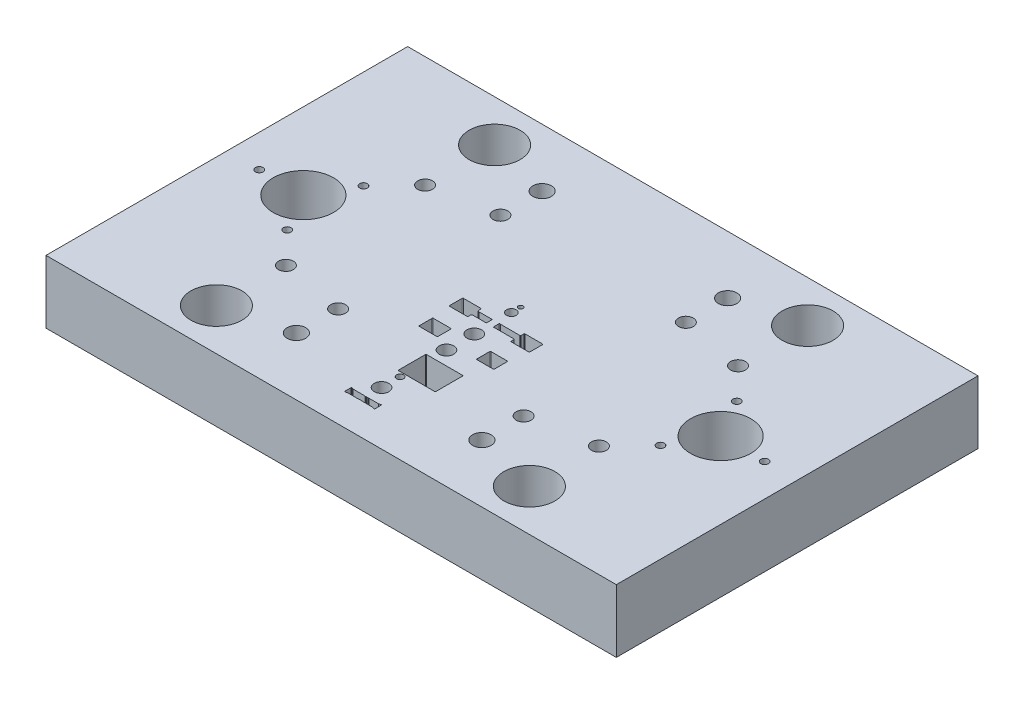
from build123d import *

# Parameters (mm, degrees)
SKETCH1_W                                           = 246
SKETCH1_H                                           = 27.2
EXTRUDE1_DEPTH                                      = 78
HOLE4_D                                             = 26
HOLE4_DEPTH                                         = 30
LPATTERN4_COUNT                                     = 2
LPATTERN4_PITCH                                     = 180
HOLE5_D                                             = 6.4
HOLE5_DEPTH                                         = 100
HOLE5_CBORE_D                                       = 25
HOLE5_CBORE_DEPTH                                   = 12
CUT_EXTRUDE4_DEPTH                                  = 1
LPATTERN5_COUNT                                     = 2
LPATTERN5_PITCH                                     = 60
LPATTERN5_COUNT_DIR2                                = 2
LPATTERN5_PITCH_DIR2                                = 135
CBORE_FOR_M6_HEX_SOCKET_HEAD_CAP_SCREW1_D           = 6.4
CBORE_FOR_M6_HEX_SOCKET_HEAD_CAP_SCREW1_CBORE_D     = 11
CBORE_FOR_M6_HEX_SOCKET_HEAD_CAP_SCREW1_CBORE_DEPTH = 8
HOLE6_D                                             = 8
M4_TAPPED_HOLE1_D                                   = 3.3
HOLE7_D                                             = 22
CUT_EXTRUDE5_DEPTH                                  = 28.2
HOLE8_D                                             = 4.2
HOLE8_DEPTH                                         = 20
HOLE9_D                                             = 6.3
HOLE9_DEPTH                                         = 20
HOLE10_D                                            = 2.06
HOLE11_D                                            = 1.5
HOLE11_CBORE_D                                      = 3
HOLE11_CBORE_DEPTH                                  = 18
SKETCH38_W                                          = 21
SKETCH38_H                                          = 23
CUT_EXTRUDE6_DEPTH                                  = 6
CUT_EXTRUDE7_DEPTH                                  = 6
SKETCH40_R                                          = 2
CUT_EXTRUDE8_DEPTH                                  = 6
M3_TAPPED_HOLE1_D                                   = 2.5
M3_TAPPED_HOLE1_DEPTH                               = 7.5
M3_TAPPED_HOLE1_TIP                                 = 0.751075774


with BuildPart() as part:
    # Sketch1 → Extrude1 (new body, symmetric)
    with BuildSketch(Plane.XY):
        with Locations((0, 13.6)):
            Rectangle(SKETCH1_W, SKETCH1_H)
    extrude(amount=EXTRUDE1_DEPTH, both=True)

    # Hole4
    with Locations(Plane.XZ):
        with Locations((90, 0)):
            hole4 = Hole(HOLE4_D / 2, depth=HOLE4_DEPTH)

    # LPattern4: Hole4 ×2
    with Locations(*[(-i * LPATTERN4_PITCH, 0, 0) for i in range(1, LPATTERN4_COUNT)]):
        add(hole4, mode=Mode.SUBTRACT)

    # Hole5
    with Locations(Plane.XZ):
        with Locations((-67.5, -30)):
            hole5 = CounterBoreHole(HOLE5_D / 2, HOLE5_CBORE_D / 2, HOLE5_CBORE_DEPTH, depth=HOLE5_DEPTH)

    # Sketch17 → Cut-Extrude4 (cut)
    with BuildSketch(Plane.XZ):
        with BuildLine():
            Line((-20, 70), (-20, -70))
            ThreePointArc((-20, -70), (-18.535533906, -73.535533906), (-15, -75))
            Line((-15, -75), (15, -75))
            ThreePointArc((15, -75), (18.535533906, -73.535533906), (20, -70))
            Line((20, -70), (20, 70))
            ThreePointArc((20, 70), (18.535533906, 73.535533906), (15, 75))
            Line((15, 75), (-15, 75))
            ThreePointArc((-15, 75), (-18.535533906, 73.535533906), (-20, 70))
        make_face()
    extrude(amount=-CUT_EXTRUDE4_DEPTH, mode=Mode.SUBTRACT)

    # LPattern5: Hole5 2 × 2
    with Locations(*[(j * LPATTERN5_PITCH_DIR2, 0, i * LPATTERN5_PITCH) for i in range(LPATTERN5_COUNT) for j in range(LPATTERN5_COUNT_DIR2) if (i, j) != (0, 0)]):
        add(hole5, mode=Mode.SUBTRACT)

    # CBORE for M6 Hex Socket Head Cap Screw1 (through all)
    with Locations(Plane.XZ):
        with Locations((40, 35), (40, -35), (-40, -35), (-40, 35)):
            CounterBoreHole(CBORE_FOR_M6_HEX_SOCKET_HEAD_CAP_SCREW1_D / 2, CBORE_FOR_M6_HEX_SOCKET_HEAD_CAP_SCREW1_CBORE_D / 2, CBORE_FOR_M6_HEX_SOCKET_HEAD_CAP_SCREW1_CBORE_DEPTH)

    # Hole6 (through all)
    with Locations(Plane.XZ):
        with Locations((40, 53), (-40, 53), (-40, -53), (40, -53)):
            Hole(HOLE6_D / 2)

    # M4 Tapped Hole1 (through all)
    with Locations(Plane.XZ):
        with Locations((-80.5, 16.454482672), (-80.5, -16.454482672), (-109, 0), (109, 0), (80.5, 16.454482672), (80.5, -16.454482672)):
            Hole(M4_TAPPED_HOLE1_D / 2)

    # Hole7 (through all)
    with Locations(Plane.XZ):
        with Locations((-67.5, 60), (67.5, 60), (67.5, -60), (-67.5, -60)):
            Hole(HOLE7_D / 2)

    # Sketch27 → Cut-Extrude5 (cut, through all)
    with BuildSketch(Plane.XZ):
        with BuildLine():
            Line((17.43, 4.3), (17.43, 9.7))
            ThreePointArc((17.43, 9.7), (17.347989899, 9.897989899), (17.15, 9.98))
            Line((17.15, 9.98), (9.65, 9.98))
            ThreePointArc((9.65, 9.98), (9.452010101, 9.897989899), (9.37, 9.7))
            Line((9.37, 9.7), (9.37, 8.589389058))
            ThreePointArc((9.37, 8.589389058), (9.343105577, 8.483983953), (9.268997853, 8.404349844))
            Line((9.268997853, 8.404349844), (9.1455495, 8.324960785))
            ThreePointArc((9.1455495, 8.324960785), (9.088565245, 8.298921073), (9.026551647, 8.29))
            Line((9.026551647, 8.29), (0.704640419, 8.29))
            ThreePointArc((0.704640419, 8.29), (0.66643782, 8.293342294), (0.629395988, 8.303267623))
            Line((0.629395988, 8.303267623), (0.602343472, 8.313113934))
            ThreePointArc((0.602343472, 8.313113934), (0.34597643, 8.279362572), (0.226577832, 8.05))
            Line((0.226577832, 8.05), (0.226577832, 5.95))
            ThreePointArc((0.226577832, 5.95), (0.34597643, 5.720637428), (0.602343472, 5.686886066))
            Line((0.602343472, 5.686886066), (0.629395988, 5.696732377))
            ThreePointArc((0.629395988, 5.696732377), (0.66643782, 5.706657706), (0.704640419, 5.71))
            Line((0.704640419, 5.71), (9.026551647, 5.71))
            ThreePointArc((9.026551647, 5.71), (9.088565245, 5.701078927), (9.1455495, 5.675039215))
            Line((9.1455495, 5.675039215), (9.268997853, 5.595650156))
            ThreePointArc((9.268997853, 5.595650156), (9.343105577, 5.516016047), (9.37, 5.410610942))
            Line((9.37, 5.410610942), (9.37, 4.3))
            ThreePointArc((9.37, 4.3), (9.452010101, 4.102010101), (9.65, 4.02))
            Line((9.65, 4.02), (17.15, 4.02))
            ThreePointArc((17.15, 4.02), (17.347989899, 4.102010101), (17.43, 4.3))
        make_face()
        with BuildLine():
            Line((-3.141125221, 8.323113934), (-3.195652511, 8.303267623))
            ThreePointArc((-3.195652511, 8.303267623), (-3.232694343, 8.293342294), (-3.270896942, 8.29))
            Line((-3.270896942, 8.29), (-8.506935091, 8.29))
            ThreePointArc((-8.506935091, 8.29), (-8.540356192, 8.292553386), (-8.573001502, 8.300154272))
            Line((-8.573001502, 8.300154272), (-8.957877828, 8.421326134))
            ThreePointArc((-8.957877828, 8.421326134), (-9.007336904, 8.446375089), (-9.046106229, 8.486005757))
            ThreePointArc((-9.046106229, 8.486005757), (-9.05851717, 8.506733681), (-9.067864493, 8.529011605))
            ThreePointArc((-9.067864493, 8.529011605), (-9.12585643, 8.761339385), (-9.145359581, 9))
            Line((-9.145359581, 9), (-9.145359581, 9.7))
            ThreePointArc((-9.145359581, 9.7), (-9.227369682, 9.897989899), (-9.425359581, 9.98))
            Line((-9.425359581, 9.98), (-16.925359581, 9.98))
            ThreePointArc((-16.925359581, 9.98), (-17.12334948, 9.897989899), (-17.205359581, 9.7))
            Line((-17.205359581, 9.7), (-17.205359581, 4.3))
            ThreePointArc((-17.205359581, 4.3), (-17.12334948, 4.102010101), (-16.925359581, 4.02))
            Line((-16.925359581, 4.02), (-9.425359581, 4.02))
            ThreePointArc((-9.425359581, 4.02), (-9.227369682, 4.102010101), (-9.145359581, 4.3))
            Line((-9.145359581, 4.3), (-9.145359581, 5))
            ThreePointArc((-9.145359581, 5), (-9.12585643, 5.238660615), (-9.067864493, 5.470988395))
            ThreePointArc((-9.067864493, 5.470988395), (-9.05851717, 5.493266319), (-9.046106229, 5.513994243))
            ThreePointArc((-9.046106229, 5.513994243), (-9.007336904, 5.553624911), (-8.957877828, 5.578673866))
            Line((-8.957877828, 5.578673866), (-8.573001502, 5.699845728))
            ThreePointArc((-8.573001502, 5.699845728), (-8.540356192, 5.707446614), (-8.506935091, 5.71))
            Line((-8.506935091, 5.71), (-3.270896942, 5.71))
            ThreePointArc((-3.270896942, 5.71), (-3.232694343, 5.706657706), (-3.195652511, 5.696732377))
            Line((-3.195652511, 5.696732377), (-3.141125221, 5.676886066))
            ThreePointArc((-3.141125221, 5.676886066), (-2.884758179, 5.710637428), (-2.765359581, 5.94))
            Line((-2.765359581, 5.94), (-2.765359581, 8.06))
            ThreePointArc((-2.765359581, 8.06), (-2.884758179, 8.289362572), (-3.141125221, 8.323113934))
        make_face()
        with BuildLine():
            Line((-16.225359581, 23.75), (-16.225359581, 18.25))
            ThreePointArc((-16.225359581, 18.25), (-16.14334948, 18.052010101), (-15.945359581, 17.97))
            Line((-15.945359581, 17.97), (-8.445359581, 17.97))
            ThreePointArc((-8.445359581, 17.97), (-8.247369682, 18.052010101), (-8.165359581, 18.25))
            Line((-8.165359581, 18.25), (-8.165359581, 23.75))
            ThreePointArc((-8.165359581, 23.75), (-8.247369682, 23.947989899), (-8.445359581, 24.03))
            Line((-8.445359581, 24.03), (-15.945359581, 24.03))
            ThreePointArc((-15.945359581, 24.03), (-16.14334948, 23.947989899), (-16.225359581, 23.75))
        make_face()
        with BuildLine():
            Line((8.62, 23.75), (8.62, 18.25))
            ThreePointArc((8.62, 18.25), (8.702010101, 18.052010101), (8.9, 17.97))
            Line((8.9, 17.97), (15.9, 17.97))
            ThreePointArc((15.9, 17.97), (16.097989899, 18.052010101), (16.18, 18.25))
            Line((16.18, 18.25), (16.18, 23.75))
            ThreePointArc((16.18, 23.75), (16.097989899, 23.947989899), (15.9, 24.03))
            Line((15.9, 24.03), (8.9, 24.03))
            ThreePointArc((8.9, 24.03), (8.702010101, 23.947989899), (8.62, 23.75))
        make_face()
        with BuildLine():
            Line((11.934640419, 33.25), (11.934640419, 44.75))
            ThreePointArc((11.934640419, 44.75), (11.852630318, 44.947989899), (11.654640419, 45.03))
            Line((11.654640419, 45.03), (-3.845359581, 45.03))
            ThreePointArc((-3.845359581, 45.03), (-4.04334948, 44.947989899), (-4.125359581, 44.75))
            Line((-4.125359581, 44.75), (-4.125359581, 33.25))
            ThreePointArc((-4.125359581, 33.25), (-4.04334948, 33.052010101), (-3.845359581, 32.97))
            Line((-3.845359581, 32.97), (11.654640419, 32.97))
            ThreePointArc((11.654640419, 32.97), (11.852630318, 33.052010101), (11.934640419, 33.25))
        make_face()
        with BuildLine():
            Line((-6.783149965, 64.28), (-7.423625234, 64.513113934))
            ThreePointArc((-7.423625234, 64.513113934), (-7.679992277, 64.479362572), (-7.799390874, 64.25))
            Line((-7.799390874, 64.25), (-7.799390874, 61.75))
            ThreePointArc((-7.799390874, 61.75), (-7.679992277, 61.520637428), (-7.423625234, 61.486886066))
            Line((-7.423625234, 61.486886066), (-6.783149965, 61.72))
            Line((-6.783149965, 61.72), (-1.795359581, 61.72))
            ThreePointArc((-1.795359581, 61.72), (-1.706815806, 61.734368677), (-1.627359581, 61.776))
            ThreePointArc((-1.627359581, 61.776), (-1.495359581, 61.82), (-1.363359581, 61.776))
            ThreePointArc((-1.363359581, 61.776), (-1.195359581, 61.72), (-1.027359581, 61.776))
            ThreePointArc((-1.027359581, 61.776), (-0.895359581, 61.82), (-0.763359581, 61.776))
            ThreePointArc((-0.763359581, 61.776), (-0.595359581, 61.72), (-0.427359581, 61.776))
            ThreePointArc((-0.427359581, 61.776), (-0.295359581, 61.82), (-0.163359581, 61.776))
            ThreePointArc((-0.163359581, 61.776), (-0.083903355, 61.734368677), (0.004640419, 61.72))
            Line((0.004640419, 61.72), (4.244368216, 61.72))
            Line((4.244368216, 61.72), (4.884843485, 61.486886066))
            ThreePointArc((4.884843485, 61.486886066), (5.141210528, 61.520637428), (5.260609126, 61.75))
            Line((5.260609126, 61.75), (5.260609126, 64.25))
            ThreePointArc((5.260609126, 64.25), (5.141210528, 64.479362572), (4.884843485, 64.513113934))
            Line((4.884843485, 64.513113934), (4.244368216, 64.28))
            Line((4.244368216, 64.28), (0.004640419, 64.28))
            ThreePointArc((0.004640419, 64.28), (-0.083903355, 64.265631323), (-0.163359581, 64.224))
            ThreePointArc((-0.163359581, 64.224), (-0.295359581, 64.18), (-0.427359581, 64.224))
            ThreePointArc((-0.427359581, 64.224), (-0.595359581, 64.28), (-0.763359581, 64.224))
            ThreePointArc((-0.763359581, 64.224), (-0.895359581, 64.18), (-1.027359581, 64.224))
            ThreePointArc((-1.027359581, 64.224), (-1.195359581, 64.28), (-1.363359581, 64.224))
            ThreePointArc((-1.363359581, 64.224), (-1.495359581, 64.18), (-1.627359581, 64.224))
            ThreePointArc((-1.627359581, 64.224), (-1.706815806, 64.265631323), (-1.795359581, 64.28))
            Line((-1.795359581, 64.28), (-6.783149965, 64.28))
        make_face()
    extrude(amount=-CUT_EXTRUDE5_DEPTH, mode=Mode.SUBTRACT)

    # Hole8
    with Locations(Plane(origin=(0, 27.2, 0), x_dir=(1, 0, 0), z_dir=(0, 1, 0))):
        with Locations((-1.269390874, 1)):
            Hole(HOLE8_D / 2, depth=HOLE8_DEPTH)

    # Hole9
    with Locations(Plane(origin=(0, 27.2, 0), x_dir=(1, 0, 0), z_dir=(0, 1, 0))):
        with Locations((-1.269390874, -15), (-1.269390874, -27), (-1.269390874, -55)):
            Hole(HOLE9_D / 2, depth=HOLE9_DEPTH)

    # Hole10 (through all)
    with Locations(Plane(origin=(0, 0, 0), x_dir=(-1, 0, 0), z_dir=(0, -1, 0))):
        with Locations((1.269390874, 5)):
            Hole(HOLE10_D / 2)

    # Hole11 (through all)
    with Locations(Plane(origin=(0, 27.2, 0), x_dir=(1, 0, 0), z_dir=(0, 1, 0))):
        with Locations((-1.269390874, -47)):
            CounterBoreHole(HOLE11_D / 2, HOLE11_CBORE_D / 2, HOLE11_CBORE_DEPTH)

    # Sketch38 → Cut-Extrude6 (cut)
    with BuildSketch(Plane.XZ):
        with Locations((-16, 49)):
            Rectangle(SKETCH38_W, SKETCH38_H)
    extrude(amount=-CUT_EXTRUDE6_DEPTH, mode=Mode.SUBTRACT)

    # Sketch39 → Cut-Extrude7 (cut)
    with BuildSketch(Plane.XZ):
        with BuildLine():
            Line((-5.5, 45.781754163), (-0.5, 45.781754163))
            ThreePointArc((-0.5, 45.781754163), (1.75, 48.031754163), (-0.5, 50.281754163))
            Line((-0.5, 50.281754163), (-5.5, 50.281754163))
            Line((-5.5, 50.281754163), (-5.5, 45.781754163))
        make_face()
        with BuildLine():
            Line((-26.5, 50.281754163), (-33.5, 50.281754163))
            ThreePointArc((-33.5, 50.281754163), (-35.75, 48.031754163), (-33.5, 45.781754163))
            Line((-33.5, 45.781754163), (-26.5, 45.781754163))
            Line((-26.5, 45.781754163), (-26.5, 50.281754163))
        make_face()
    extrude(amount=-CUT_EXTRUDE7_DEPTH, mode=Mode.SUBTRACT)

    # Sketch40 → Cut-Extrude8 (cut)
    with BuildSketch(Plane.XZ):
        with Locations((-7.5, 37.5)):
            Circle(SKETCH40_R)
        with Locations((-24.5, 37.5)):
            Circle(SKETCH40_R)
        with Locations((-24.5, 60.5)):
            Circle(SKETCH40_R)
        with Locations((-7.5, 60.5)):
            Circle(SKETCH40_R)
    extrude(amount=-CUT_EXTRUDE8_DEPTH, mode=Mode.SUBTRACT)

    # M3 Tapped Hole1
    with Locations(Plane(origin=(0, 6, 0), x_dir=(-1, 0, 0), z_dir=(0, -1, 0))):
        with Locations((11, -55), (21, -55)):
            Hole(M3_TAPPED_HOLE1_D / 2, depth=M3_TAPPED_HOLE1_DEPTH)
            with Locations((0, 0, -(M3_TAPPED_HOLE1_DEPTH + M3_TAPPED_HOLE1_TIP / 2))):  # 118° drill point
                Cone(0, M3_TAPPED_HOLE1_D / 2, M3_TAPPED_HOLE1_TIP, mode=Mode.SUBTRACT)


solid = part.part
